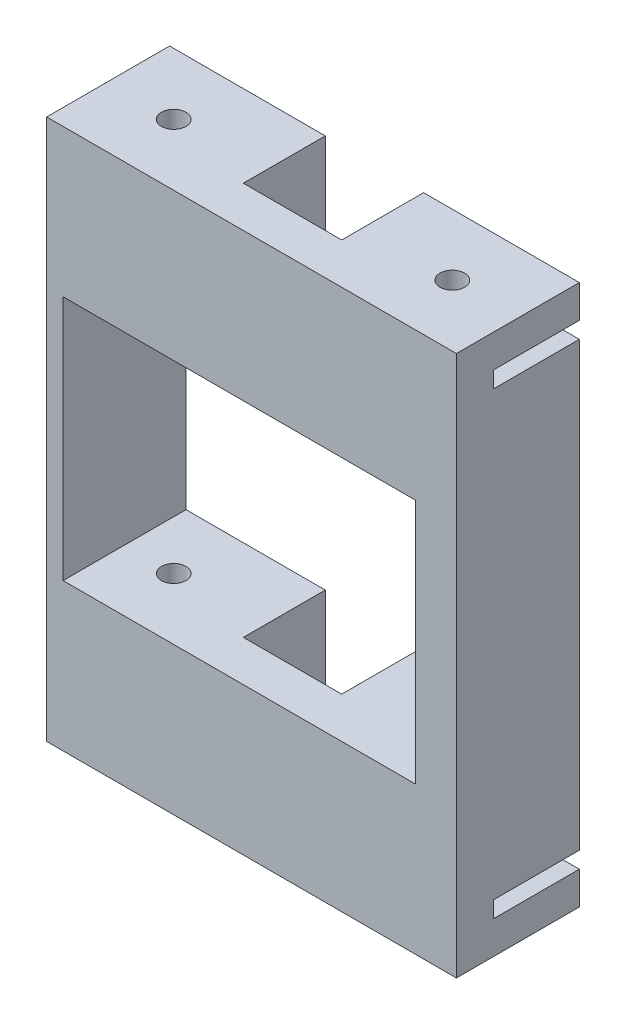
from build123d import *

# Parameters (mm, degrees)
CROQUIS1_W              = 50
CROQUIS1_H              = 66
CROQUIS1_W_2            = 43
CROQUIS1_H_2            = 30
SALIENTE_EXTRUIR1_DEPTH = 15
CROQUIS2_R              = 1.5
CROQUIS2_W              = 12
CROQUIS2_H              = 10
CORTAR_EXTRUIR5_DEPTH   = 67
CROQUIS3_W              = 10.5
CROQUIS3_H              = 2
CORTAR_EXTRUIR2_DEPTH   = 12
CROQUIS5_W              = 10.5
CROQUIS5_H              = 2
CORTAR_EXTRUIR3_DEPTH   = 12


with BuildPart() as part:
    # Croquis1 → Saliente-Extruir1 (new body)
    with BuildSketch(Plane.XY):
        with Locations((25, 33)):
            Rectangle(CROQUIS1_W, CROQUIS1_H)
        with Locations((23.5, 33)):
            Rectangle(CROQUIS1_W_2, CROQUIS1_H_2, mode=Mode.SUBTRACT)
    extrude(amount=SALIENTE_EXTRUIR1_DEPTH)

    # Croquis2 → Cortar-Extruir5 (cut, through all)
    with BuildSketch(Plane.XZ):
        with Locations(Location((42, 7.5, 0), (0, 0, 270))):  # turned: the seam where the file's is
            Circle(CROQUIS2_R)
        with Locations(Location((8, 7.5, 0), (0, 0, 270))):  # turned: the seam where the file's is
            Circle(CROQUIS2_R)
        with Locations((25, 5)):
            Rectangle(CROQUIS2_W, CROQUIS2_H)
    extrude(amount=-CORTAR_EXTRUIR5_DEPTH, mode=Mode.SUBTRACT)

    # Croquis3 → Cortar-Extruir2 (cut)
    with BuildSketch(Plane.ZY):
        with Locations((5.25, 61)):
            Rectangle(CROQUIS3_W, CROQUIS3_H)
        with Locations((5.25, 5)):
            Rectangle(CROQUIS3_W, CROQUIS3_H)
    extrude(amount=-CORTAR_EXTRUIR2_DEPTH, mode=Mode.SUBTRACT)

    # Croquis5 → Cortar-Extruir3 (cut)
    with BuildSketch(Plane(origin=(50, 0, 0), x_dir=(0, 0, -1), z_dir=(1, 0, 0))):
        with Locations((-5.25, 5)):
            Rectangle(CROQUIS5_W, CROQUIS5_H)
        with Locations((-5.25, 61)):
            Rectangle(CROQUIS5_W, CROQUIS5_H)
    extrude(amount=-CORTAR_EXTRUIR3_DEPTH, mode=Mode.SUBTRACT)


solid = part.part
